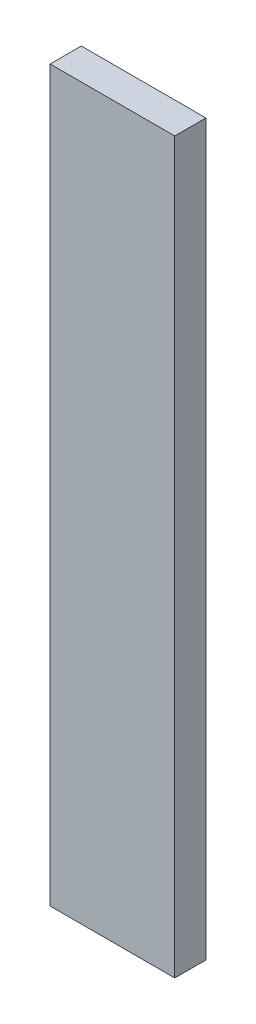
from build123d import *

# Parameters (mm, degrees)
SKETCH1_W           = 40
SKETCH1_H           = 10
BOSS_EXTRUDE1_DEPTH = 234


with BuildPart() as part:
    # Sketch1 → Boss-Extrude1 (new body)
    with BuildSketch(Plane(origin=(0, 0, 0), x_dir=(1, 0, 0), z_dir=(0, 1, 0))):
        Rectangle(SKETCH1_W, SKETCH1_H)
    extrude(amount=BOSS_EXTRUDE1_DEPTH)


solid = part.part
